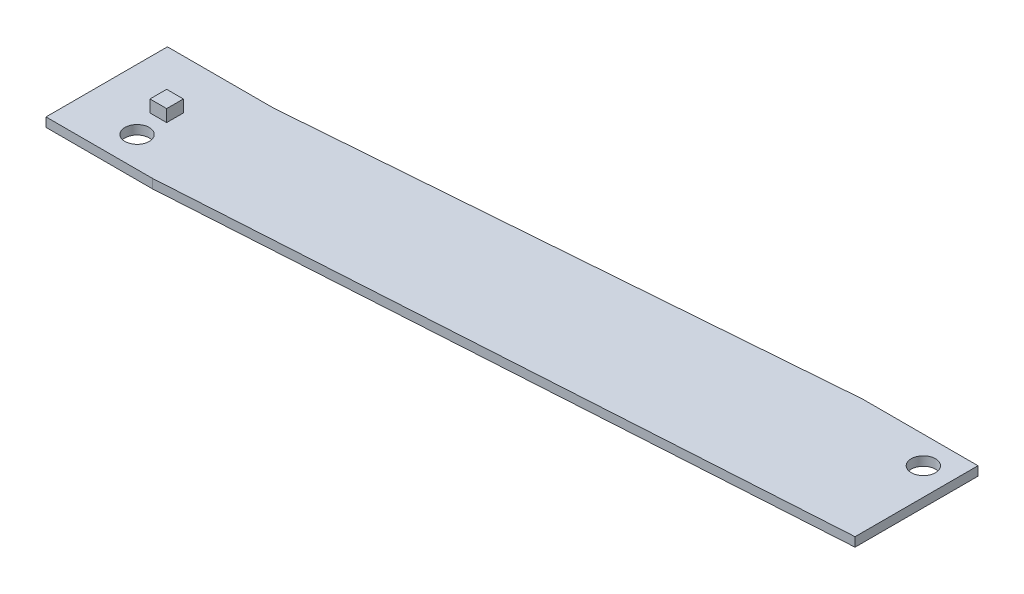
from build123d import *

# Parameters (mm, degrees)
BOSS_EXTRUDE1_DEPTH = 1.2
SKETCH2_R           = 1.6
CUT_EXTRUDE1_DEPTH  = 1.2
SKETCH3_W           = 2.2
SKETCH3_H           = 2.2
BOSS_EXTRUDE2_DEPTH = 1.6


with BuildPart() as part:
    # Sketch1 → Boss-Extrude1 (new body)
    with BuildSketch(Plane(origin=(0, 0, 0), x_dir=(1, 0, 0), z_dir=(0, 1, 0))):
        Polygon((87.2, 5.6), (72, 5.6), (0, 0), (-14, 0), (-14, -16), (0, -16), (87.2, -10.6), align=None)
    extrude(amount=BOSS_EXTRUDE1_DEPTH)

    # Sketch2 → Cut-Extrude1 (cut)
    with BuildSketch(Plane(origin=(0, 1.2, 0), x_dir=(1, 0, 0), z_dir=(0, 1, 0))):
        with Locations((-6, -12)):
            Circle(SKETCH2_R)
        with Locations((83.6, 2)):
            Circle(SKETCH2_R)
    extrude(amount=-CUT_EXTRUDE1_DEPTH, mode=Mode.SUBTRACT)

    # Sketch3 → Boss-Extrude2 (add)
    with BuildSketch(Plane(origin=(0, 1.2, 0), x_dir=(1, 0, 0), z_dir=(0, 1, 0))):
        with Locations((-6.5, -7.6)):
            Rectangle(SKETCH3_W, SKETCH3_H)
    extrude(amount=BOSS_EXTRUDE2_DEPTH)


solid = part.part
